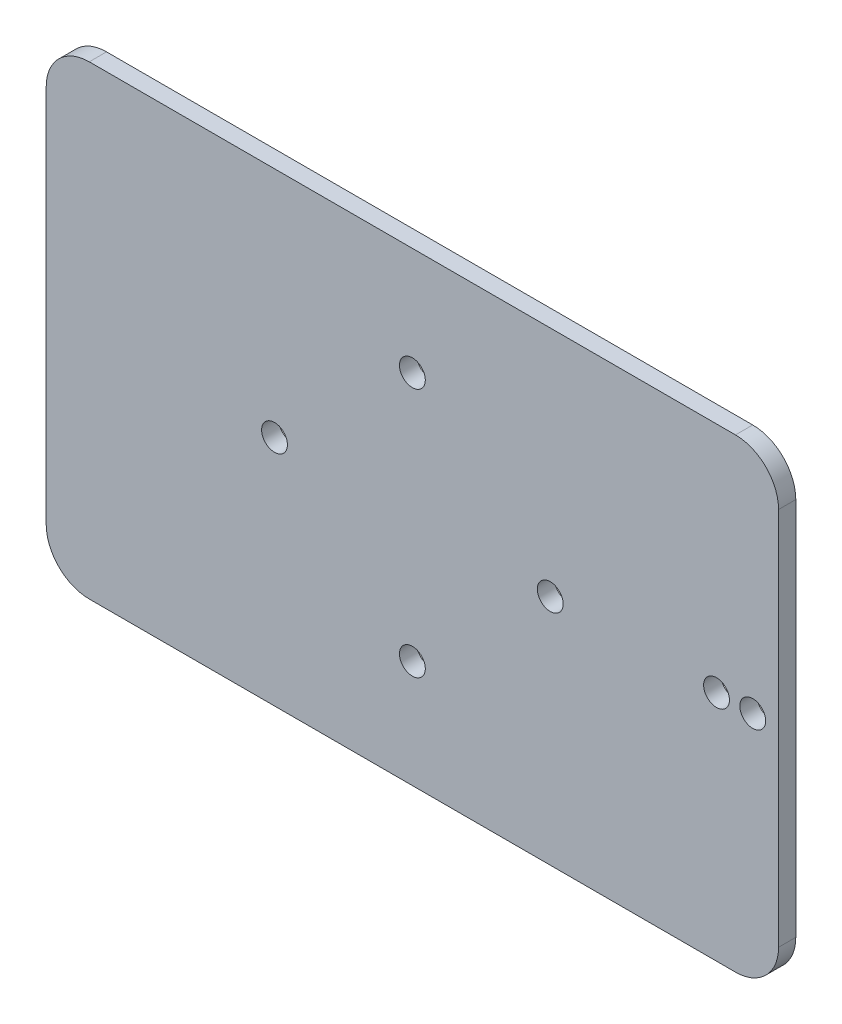
from build123d import *

# Parameters (mm, degrees)
SKETCH_1_W      = 85
SKETCH_1_H      = 54
SKETCH_1_R      = 1.5
EXTRUDE_1_DEPTH = 2
FILLET_1_R      = 5


with BuildPart() as part:
    # 草图1 → 凸台-拉伸1 (new body)
    with BuildSketch(Plane.XY):
        Rectangle(SKETCH_1_W, SKETCH_1_H)
        with Locations((39.5, 0)):
            Circle(SKETCH_1_R, mode=Mode.SUBTRACT)
        with Locations((35.3, 0)):
            Circle(SKETCH_1_R, mode=Mode.SUBTRACT)
        with Locations((0, 14.5)):
            Circle(SKETCH_1_R, mode=Mode.SUBTRACT)
        with Locations((-16, 0)):
            Circle(SKETCH_1_R, mode=Mode.SUBTRACT)
        with Locations((16, 0)):
            Circle(SKETCH_1_R, mode=Mode.SUBTRACT)
        with Locations((0, -14.5)):
            Circle(SKETCH_1_R, mode=Mode.SUBTRACT)
    extrude(amount=EXTRUDE_1_DEPTH)

    # 圆角1
    fillet_1_edges = [part.edges().sort_by_distance(p)[0] for p in [
        (42.5, -27, 1),
        (-42.5, -27, 1),
        (-42.5, 27, 1),
        (42.5, 27, 1),
    ]]
    fillet(fillet_1_edges, radius=FILLET_1_R)


solid = part.part
